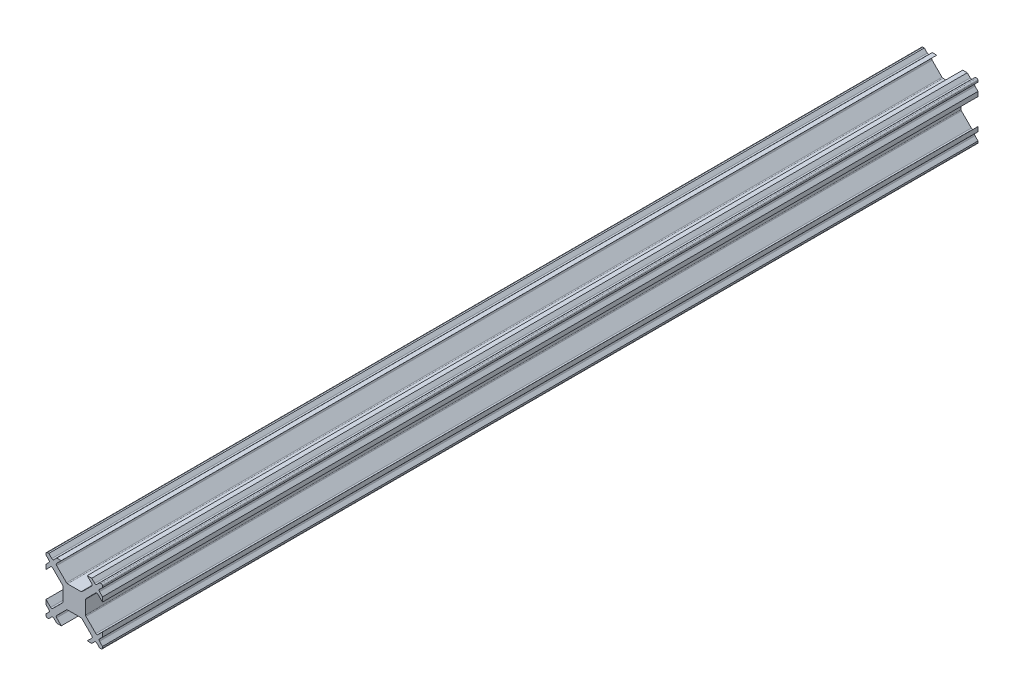
from build123d import *

# Parameters (mm, degrees)
BOSS_EXTRUDE1_DEPTH      = 155
CIRPATTERN4_COUNT        = 4
CIRPATTERN4_COPY_1_DEPTH = 155
CIRPATTERN4_COPY_2_DEPTH = 155
CIRPATTERN4_COPY_3_DEPTH = 155


with BuildPart() as part:
    # Sketch2 → Boss-Extrude1 (new body)
    with BuildSketch(Plane.XY):
        with BuildLine():
            Line((-1.366116524, 2.073223305), (-3.116116524, 3.823223305))
            ThreePointArc((-3.116116524, 3.823223305), (-3.189339828, 4), (-3.116116524, 4.176776695))
            Line((-3.116116524, 4.176776695), (-2.292893219, 5))
            Line((-2.292893219, 5), (-3.094974747, 5))
            Line((-3.094974747, 5), (-3.623223305, 4.471751442))
            ThreePointArc((-3.623223305, 4.471751442), (-3.8, 4.398528137), (-3.976776695, 4.471751442))
            Line((-3.976776695, 4.471751442), (-4.505025253, 5))
            Line((-4.505025253, 5), (-4.75, 5))
            ThreePointArc((-4.75, 5), (-4.845670858, 4.980969883), (-4.926776695, 4.926776695))
            Line((-4.926776695, 4.926776695), (0, 0))
            Line((0, 0), (0, 2))
            Line((0, 2), (-1.189339828, 2))
            ThreePointArc((-1.189339828, 2), (-1.285010686, 2.019030117), (-1.366116524, 2.073223305))
        make_face()
    boss_extrude1 = extrude(amount=BOSS_EXTRUDE1_DEPTH)

    # Mirror1: Boss-Extrude1 across plane
    add(boss_extrude1.mirror(Plane(origin=(0, 0, 155), x_dir=(0, 0, 1), z_dir=(0.707106781, 0.707106781, 0))))

    # CirPattern4: Boss-Extrude1 ×4 about axis
    cirpattern4_axis = Axis((0, 0, 0), (0, 0, 1))
    for i in range(1, CIRPATTERN4_COUNT):
        add(boss_extrude1.rotate(cirpattern4_axis, i * 360 / CIRPATTERN4_COUNT))

    # CirPattern4 copy 1 sketch → CirPattern4 copy 1 (add)
    with BuildSketch(Plane.XY):
        with BuildLine():
            Line((-1.366116524, -2.073223305), (-3.116116524, -3.823223305))
            ThreePointArc((-3.116116524, -3.823223305), (-3.189339828, -4), (-3.116116524, -4.176776695))
            Line((-3.116116524, -4.176776695), (-2.292893219, -5))
            Line((-2.292893219, -5), (-3.094974747, -5))
            Line((-3.094974747, -5), (-3.623223305, -4.471751442))
            ThreePointArc((-3.623223305, -4.471751442), (-3.8, -4.398528137), (-3.976776695, -4.471751442))
            Line((-3.976776695, -4.471751442), (-4.505025253, -5))
            Line((-4.505025253, -5), (-4.75, -5))
            ThreePointArc((-4.75, -5), (-4.845670858, -4.980969883), (-4.926776695, -4.926776695))
            Line((-4.926776695, -4.926776695), (0, 0))
            Line((0, 0), (0, -2))
            Line((0, -2), (-1.189339828, -2))
            ThreePointArc((-1.189339828, -2), (-1.285010686, -2.019030117), (-1.366116524, -2.073223305))
        make_face()
    extrude(amount=CIRPATTERN4_COPY_1_DEPTH)

    # CirPattern4 copy 2 sketch → CirPattern4 copy 2 (add)
    with BuildSketch(Plane(origin=(0, 0, 0), x_dir=(0, 1, 0), z_dir=(0, 0, 1))):
        with BuildLine():
            Line((-1.366116524, -2.073223305), (-3.116116524, -3.823223305))
            ThreePointArc((-3.116116524, -3.823223305), (-3.189339828, -4), (-3.116116524, -4.176776695))
            Line((-3.116116524, -4.176776695), (-2.292893219, -5))
            Line((-2.292893219, -5), (-3.094974747, -5))
            Line((-3.094974747, -5), (-3.623223305, -4.471751442))
            ThreePointArc((-3.623223305, -4.471751442), (-3.8, -4.398528137), (-3.976776695, -4.471751442))
            Line((-3.976776695, -4.471751442), (-4.505025253, -5))
            Line((-4.505025253, -5), (-4.75, -5))
            ThreePointArc((-4.75, -5), (-4.845670858, -4.980969883), (-4.926776695, -4.926776695))
            Line((-4.926776695, -4.926776695), (0, 0))
            Line((0, 0), (0, -2))
            Line((0, -2), (-1.189339828, -2))
            ThreePointArc((-1.189339828, -2), (-1.285010686, -2.019030117), (-1.366116524, -2.073223305))
        make_face()
    extrude(amount=CIRPATTERN4_COPY_2_DEPTH)

    # CirPattern4 copy 3 sketch → CirPattern4 copy 3 (add)
    with BuildSketch(Plane(origin=(0, 0, 0), x_dir=(-1, 0, 0), z_dir=(0, 0, 1))):
        with BuildLine():
            Line((-1.366116524, -2.073223305), (-3.116116524, -3.823223305))
            ThreePointArc((-3.116116524, -3.823223305), (-3.189339828, -4), (-3.116116524, -4.176776695))
            Line((-3.116116524, -4.176776695), (-2.292893219, -5))
            Line((-2.292893219, -5), (-3.094974747, -5))
            Line((-3.094974747, -5), (-3.623223305, -4.471751442))
            ThreePointArc((-3.623223305, -4.471751442), (-3.8, -4.398528137), (-3.976776695, -4.471751442))
            Line((-3.976776695, -4.471751442), (-4.505025253, -5))
            Line((-4.505025253, -5), (-4.75, -5))
            ThreePointArc((-4.75, -5), (-4.845670858, -4.980969883), (-4.926776695, -4.926776695))
            Line((-4.926776695, -4.926776695), (0, 0))
            Line((0, 0), (0, -2))
            Line((0, -2), (-1.189339828, -2))
            ThreePointArc((-1.189339828, -2), (-1.285010686, -2.019030117), (-1.366116524, -2.073223305))
        make_face()
    extrude(amount=CIRPATTERN4_COPY_3_DEPTH)


solid = part.part
